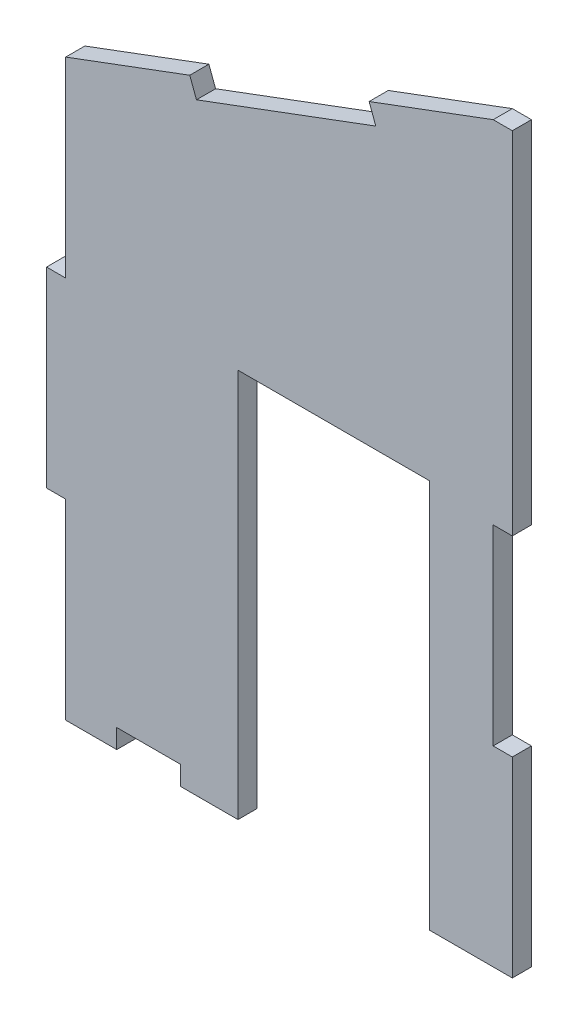
from build123d import *

# Parameters (mm, degrees)
BOSS_EXTRUDE1_DEPTH = 3


with BuildPart() as part:
    # Model → Boss-Extrude1 (new body)
    with BuildSketch(Plane.XY):
        Polygon((178.627918025, 199.123752973), (178.627918025, 169.123752973), (181.627918025, 169.123752973), (181.627918025, 139.123752973), (189.627918025, 139.123752973), (189.627918025, 142.123752973), (199.627918025, 142.123752973), (199.627918025, 139.123752973), (208.627918025, 139.123752973), (208.627918025, 200.123752973), (238.627918025, 200.123752973), (238.627918025, 139.123752973), (251.627918025, 139.123752973), (251.627918025, 169.123752973), (248.627918025, 169.123752973), (248.627918025, 199.123752973), (251.627918025, 199.123752973), (251.627918025, 254.123752973), (248.627918025, 254.123752973), (229.181456918, 246.867610769), (230.230228478, 244.056902991), (202.123150692, 233.569187399), (201.074379132, 236.379895177), (181.627918025, 229.123752973), (181.627918025, 199.123752973), align=None)
    extrude(amount=BOSS_EXTRUDE1_DEPTH)


solid = part.part
